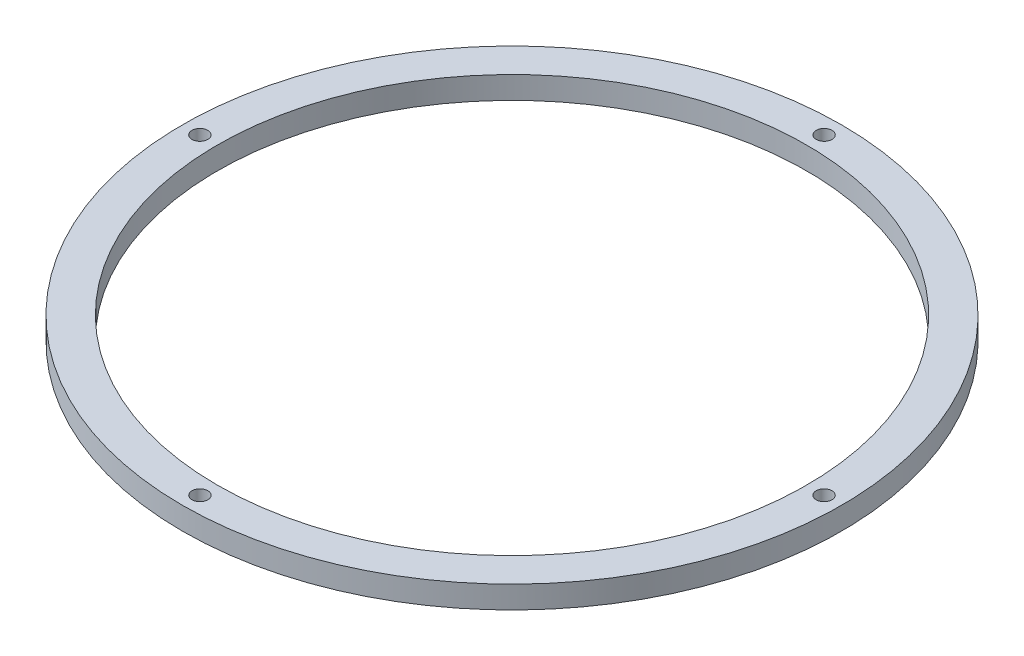
from build123d import *

# Parameters (mm, degrees)
SKETCH1_R           = 125
SKETCH1_R_2         = 111.75
BOSS_EXTRUDE1_DEPTH = 8.5
SKETCH2_R           = 3
CUT_EXTRUDE1_DEPTH  = 9.5


with BuildPart() as part:
    # Sketch1 → Boss-Extrude1 (new body)
    with BuildSketch(Plane(origin=(0, 0, 0), x_dir=(1, 0, 0), z_dir=(0, 1, 0))):
        Circle(SKETCH1_R)
        Circle(SKETCH1_R_2, mode=Mode.SUBTRACT)
    extrude(amount=BOSS_EXTRUDE1_DEPTH)

    # Sketch2 → Cut-Extrude1 (cut, through all)
    with BuildSketch(Plane(origin=(0, 8.5, 0), x_dir=(1, 0, 0), z_dir=(0, 1, 0))):
        with Locations((0, 118.375)):
            Circle(SKETCH2_R)
        with Locations((118.375, 0)):
            Circle(SKETCH2_R)
        with Locations((0, -118.375)):
            Circle(SKETCH2_R)
        with Locations((-118.375, 0)):
            Circle(SKETCH2_R)
    extrude(amount=-CUT_EXTRUDE1_DEPTH, mode=Mode.SUBTRACT)


solid = part.part
